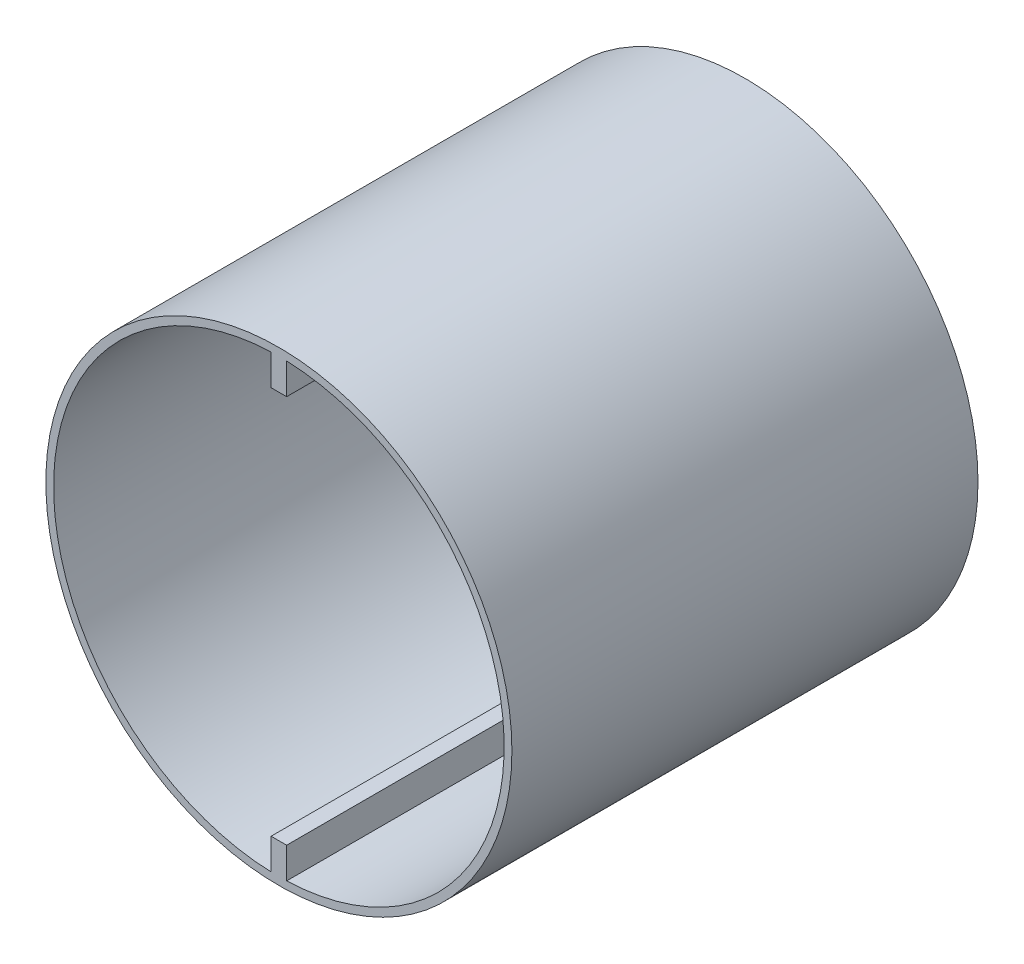
from build123d import *

# Parameters (mm, degrees)
BOSS_EXTRU_1_DEPTH      = 60
ESQUISSE2_R             = 30
ESQUISSE2_R_2           = 29
BOSS_EXTRU_2_DEPTH      = 60
ESQUISSE3_R             = 25
ENL_V_MAT_EXTRU_1_DEPTH = 27
ESQUISSE6_R             = 2.225
ENL_V_MAT_EXTRU_3_DEPTH = 2
ESQUISSE10_W            = 42
ESQUISSE10_H            = 21.645898034
ENL_V_MAT_EXTRU_7_DEPTH = 5


with BuildPart() as part:
    # Esquisse1 → Boss.-Extru.1 (new body)
    with BuildSketch(Plane.XY):
        with BuildLine():
            Line((1, -15.006468588), (1, -3.354101966))
            ThreePointArc((1, -3.354101966), (3.5, 0), (1, 3.354101966))
            Line((1, 3.354101966), (1, 29.5))
            Line((1, 29.5), (-1, 29.5))
            Line((-1, 29.5), (-1, 3.354101966))
            ThreePointArc((-1, 3.354101966), (-3.5, 0), (-1, -3.354101966))
            Line((-1, -3.354101966), (-1, -29.5))
            Line((-1, -29.5), (1, -29.5))
            Line((1, -29.5), (1, -15.006468588))
        make_face()
    extrude(amount=BOSS_EXTRU_1_DEPTH)

    # Esquisse2 → Boss.-Extru.2 (add)
    with BuildSketch(Plane.XY.offset(60)):
        Circle(ESQUISSE2_R)
        Circle(ESQUISSE2_R_2, mode=Mode.SUBTRACT)
    extrude(amount=-BOSS_EXTRU_2_DEPTH)

    # Esquisse3 → Enlèv. mat.-Extru.1 (cut)
    with BuildSketch(Plane.XY.offset(60)):
        Circle(ESQUISSE3_R)
    extrude(amount=-ENL_V_MAT_EXTRU_1_DEPTH, mode=Mode.SUBTRACT)

    # Esquisse6 → Enlèv. mat.-Extru.3 (cut)
    with BuildSketch(Plane.XY.offset(33)):
        Circle(ESQUISSE6_R)
    extrude(amount=-ENL_V_MAT_EXTRU_3_DEPTH, mode=Mode.SUBTRACT)

    # Esquisse10 → Enlèv. mat.-Extru.7 (cut)
    with BuildSketch(Plane(origin=(1, 0, 0), x_dir=(0, 0, -1), z_dir=(1, 0, 0))):
        with Locations((-39, -14.177050983)):
            Rectangle(ESQUISSE10_W, ESQUISSE10_H)
        with Locations((-39, 14.177050983)):
            Rectangle(ESQUISSE10_W, ESQUISSE10_H)
    extrude(amount=-ENL_V_MAT_EXTRU_7_DEPTH, mode=Mode.SUBTRACT)


solid = part.part
